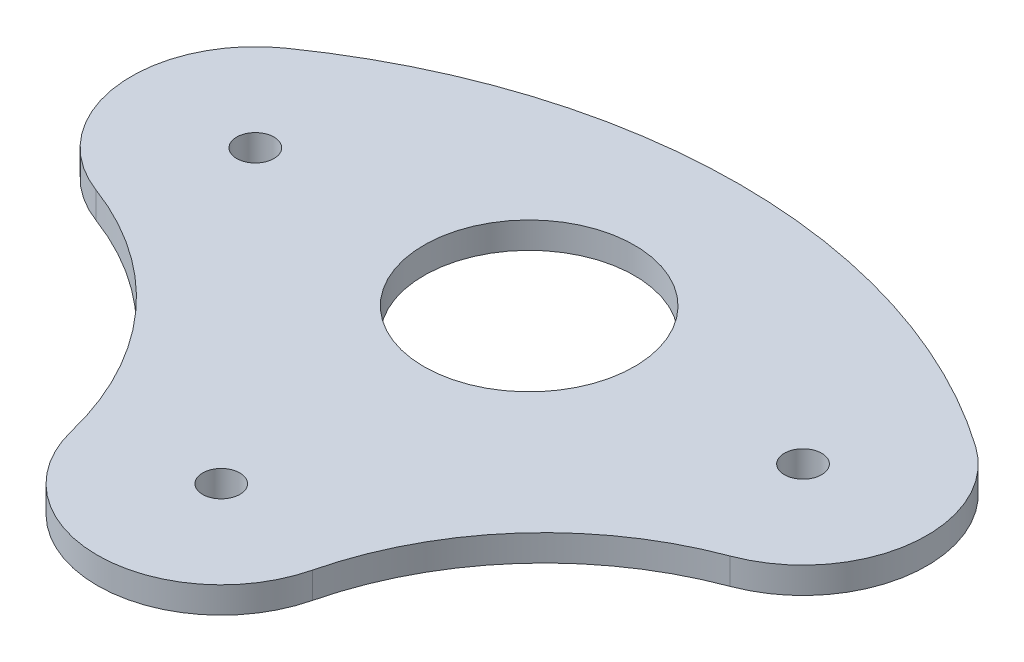
from build123d import *

# Parameters (mm, degrees)
SKETCH1_R           = 12.7
SKETCH1_R_2         = 2.25
BOSS_EXTRUDE1_DEPTH = 3.175


with BuildPart() as part:
    # Sketch1 → Boss-Extrude1 (new body)
    with BuildSketch(Plane(origin=(0, 0, 0), x_dir=(1, 0, 0), z_dir=(0, 1, 0))):
        with BuildLine():
            ThreePointArc((-41.632787539, 12.230172128), (-47.862074133, -1.911659432), (-38.249546762, -14.011028378))
            ThreePointArc((-38.249546762, -14.011028378), (-23.068421331, -24.399712606), (-14.524270984, -40.690471465))
            ThreePointArc((-14.524270984, -40.690471465), (0, -52.098148446), (14.524270984, -40.690471465))
            ThreePointArc((14.524270984, -40.690471465), (23.068421331, -24.399712606), (38.249546762, -14.011028378))
            ThreePointArc((38.249546762, -14.011028378), (47.862074133, -1.911659432), (41.632787539, 12.230172128))
            ThreePointArc((41.632787539, 12.230172128), (0, 25.4), (-41.632787539, 12.230172128))
        make_face()
        Circle(SKETCH1_R, mode=Mode.SUBTRACT)
        with Locations((-33.0348, 0)):
            Circle(SKETCH1_R_2, mode=Mode.SUBTRACT)
        with Locations((33.0348, 0)):
            Circle(SKETCH1_R_2, mode=Mode.SUBTRACT)
        with Locations((0, -37.148148446)):
            Circle(SKETCH1_R_2, mode=Mode.SUBTRACT)
    extrude(amount=BOSS_EXTRUDE1_DEPTH)


solid = part.part
